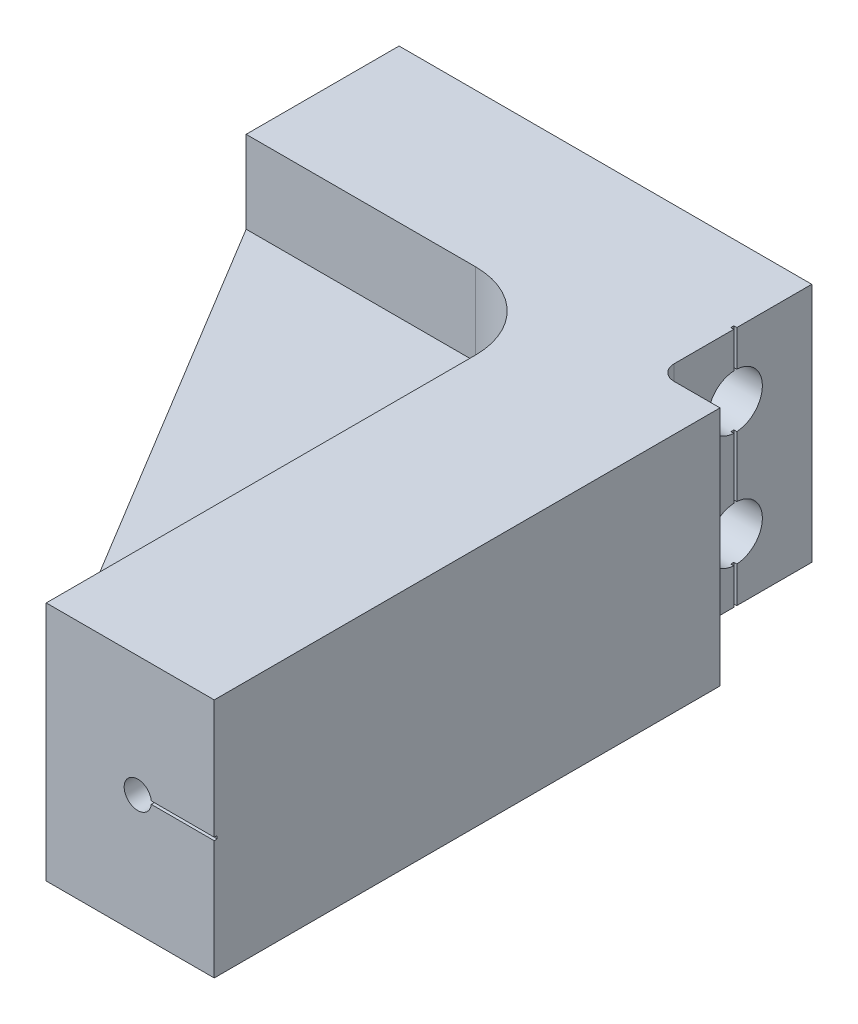
from build123d import *

# Parameters (mm, degrees)
SKETCH1_W                 = 24.25
SKETCH1_H                 = 20
EXTRUDE1_DEPTH            = 54.7
CUT_EXTRUDE1_DEPTH        = 21
SKETCH5_W                 = 12.7
SKETCH5_H                 = 20
EXTRUDE2_DEPTH            = 15.1
F_8_CLEARANCE_HOLE1_D     = 4.4958
F_4_40_TAPPED_HOLE1_D     = 2.2606
F_4_40_TAPPED_HOLE1_DEPTH = 8.8646
F_4_40_TAPPED_HOLE1_TIP   = 0.679152758
SKETCH11_W                = 12.7
SKETCH11_H                = 20
CUT_EXTRUDE2_DEPTH        = 5.08
FILLET1_R                 = 1.27
SKETCH12_W                = 0.25
SKETCH12_H                = 20
CUT_EXTRUDE3_DEPTH        = 0.25
EXTRUDE3_DEPTH            = 3.175
SKETCH14_W                = 6.35
SKETCH14_H                = 0.25
CUT_EXTRUDE4_DEPTH        = 0.25


with BuildPart() as part:
    # Sketch1 → Extrude1 (new body)
    with BuildSketch(Plane.XY):
        with Locations((12.125, 0)):
            Rectangle(SKETCH1_W, SKETCH1_H)
    extrude(amount=EXTRUDE1_DEPTH)

    # Sketch4 → Cut-Extrude1 (cut, through all)
    with BuildSketch(Plane.XZ.offset(10)):
        with BuildLine():
            Line((0, 12.7), (3.95, 12.7))
            ThreePointArc((3.95, 12.7), (8.440128061, 14.559871939), (10.3, 19.05))
            Line((10.3, 19.05), (10.3, 54.7))
            Line((10.3, 54.7), (0, 54.7))
            Line((0, 54.7), (0, 12.7))
        make_face()
    extrude(amount=-CUT_EXTRUDE1_DEPTH, mode=Mode.SUBTRACT)

    # Sketch5 → Extrude2 (add)
    with BuildSketch(Plane.ZY):
        with Locations((6.35, 0)):
            Rectangle(SKETCH5_W, SKETCH5_H)
    extrude(amount=EXTRUDE2_DEPTH)

    # #8 Clearance Hole1 (through all)
    with Locations(Plane(origin=(24.25, 0, 0), x_dir=(0, 0, -1), z_dir=(1, 0, 0))):
        with Locations((-6.35, 4.7625), (-6.35, -4.7625)):
            Hole(F_8_CLEARANCE_HOLE1_D / 2)

    # #4-40 Tapped Hole1
    with Locations(Plane.XY.offset(54.7)):
        with Locations((17.9, 0)):
            Hole(F_4_40_TAPPED_HOLE1_D / 2, depth=F_4_40_TAPPED_HOLE1_DEPTH)
            with Locations((0, 0, -(F_4_40_TAPPED_HOLE1_DEPTH + F_4_40_TAPPED_HOLE1_TIP / 2))):  # 118° drill point
                Cone(0, F_4_40_TAPPED_HOLE1_D / 2, F_4_40_TAPPED_HOLE1_TIP, mode=Mode.SUBTRACT)

    # Sketch11 → Cut-Extrude2 (cut)
    with BuildSketch(Plane(origin=(24.25, 0, 0), x_dir=(0, 0, -1), z_dir=(1, 0, 0))):
        with Locations((-6.35, 0)):
            Rectangle(SKETCH11_W, SKETCH11_H)
    extrude(amount=-CUT_EXTRUDE2_DEPTH, mode=Mode.SUBTRACT)

    # Fillet1
    fillet1_edges = [part.edges().sort_by_distance(p)[0] for p in [
        (19.17, 0, 12.7),
    ]]
    fillet(fillet1_edges, radius=FILLET1_R)

    # Sketch12 → Cut-Extrude3 (cut)
    with BuildSketch(Plane(origin=(19.17, 0, 0), x_dir=(0, 0, -1), z_dir=(1, 0, 0))):
        with Locations((-6.35, 0)):
            Rectangle(SKETCH12_W, SKETCH12_H)
    extrude(amount=-CUT_EXTRUDE3_DEPTH, mode=Mode.SUBTRACT)

    # Sketch13 → Extrude3 (add, symmetric)
    with BuildSketch(Plane(origin=(0, 0, 0), x_dir=(1, 0, 0), z_dir=(0, 1, 0))):
        Polygon((-15.1, -12.7), (10.3, -54.7), (10.3, -12.7), align=None)
    extrude(amount=EXTRUDE3_DEPTH, both=True)

    # Sketch14 → Cut-Extrude4 (cut)
    with BuildSketch(Plane.XY.offset(54.7)):
        with Locations((21.075, 0)):
            Rectangle(SKETCH14_W, SKETCH14_H)
    extrude(amount=-CUT_EXTRUDE4_DEPTH, mode=Mode.SUBTRACT)


solid = part.part
